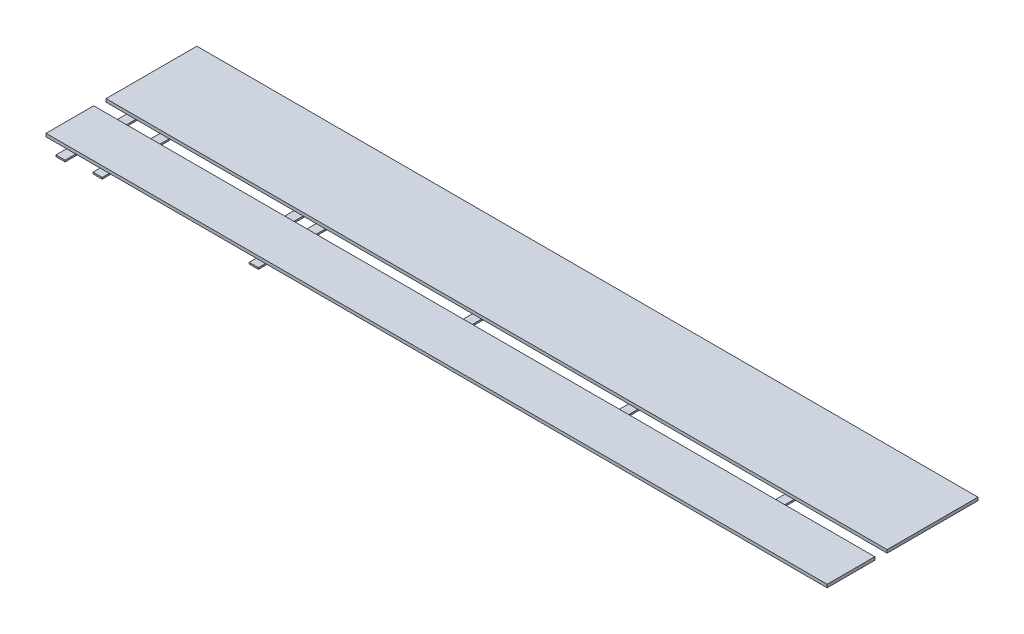
from build123d import *

# Parameters (mm, degrees)
SKETCH2_W             = 19.05
SKETCH2_H             = 251.02058
SKETCH2_R             = 2
BOSS_EXTRUDE1_DEPTH   = 3.175
BOSS_EXTRUDE1_2_DEPTH = 3.175
BOSS_EXTRUDE1_3_DEPTH = 3.175
SKETCH2_H_2           = 177.45456
BOSS_EXTRUDE1_4_DEPTH = 3.175
SKETCH2_H_3           = 125.44806
BOSS_EXTRUDE1_5_DEPTH = 3.175
SKETCH2_H_4           = 88.64092
BOSS_EXTRUDE1_6_DEPTH = 3.175
SKETCH2_H_5           = 265.9888
BOSS_EXTRUDE1_7_DEPTH = 3.175
BOSS_EXTRUDE2_DEPTH   = 6.35
BOSS_EXTRUDE2_2_DEPTH = 6.35


with BuildPart() as part:
    # Sketch2 → Boss-Extrude1 (new body)
    with BuildSketch(Plane(origin=(0, 0, 0), x_dir=(1, 0, 0), z_dir=(0, 1, 0))):
        with Locations((32.525, 177.50028)):
            Rectangle(SKETCH2_W, SKETCH2_H)
        with Locations((32.525, 246.79737)):
            Circle(SKETCH2_R, mode=Mode.SUBTRACT)
        with Locations((32.525, 108.20319)):
            Circle(SKETCH2_R, mode=Mode.SUBTRACT)
    extrude(amount=BOSS_EXTRUDE1_DEPTH)


with BuildPart() as body_2:
    # Sketch2 → Boss-Extrude1 2 (new body)
    with BuildSketch(Plane(origin=(0, 0, 0), x_dir=(1, 0, 0), z_dir=(0, 1, 0))):
        Polygon((299, 268.87678), (299, 86.12378), (318.05, 86.12378), (318.05, 268.87678), (308.525, 268.87678), align=None)
        with Locations((308.525, 227.93978)):
            Circle(SKETCH2_R, mode=Mode.SUBTRACT)
        with BuildLine():
            ThreePointArc((308.525, 125.06078), (306.525, 127.06078), (308.525, 129.06078))
            ThreePointArc((308.525, 129.06078), (310.525, 127.06078), (308.525, 125.06078))
        make_face(mode=Mode.SUBTRACT)
    extrude(amount=BOSS_EXTRUDE1_2_DEPTH)


with BuildPart() as body_3:
    # Sketch2 → Boss-Extrude1 3 (new body)
    with BuildSketch(Plane(origin=(0, 0, 0), x_dir=(1, 0, 0), z_dir=(0, 1, 0))):
        with Locations((354.525, 177.50028)):
            Rectangle(SKETCH2_W, SKETCH2_H)
        with Locations((354.525, 108.48022915)):
            Circle(SKETCH2_R, mode=Mode.SUBTRACT)
        with Locations((354.525, 246.52033085)):
            Circle(SKETCH2_R, mode=Mode.SUBTRACT)
    extrude(amount=BOSS_EXTRUDE1_3_DEPTH)


with BuildPart() as body_4:
    # Sketch2 → Boss-Extrude1 4 (new body)
    with BuildSketch(Plane(origin=(0, 0, 0), x_dir=(1, 0, 0), z_dir=(0, 1, 0))):
        with Locations((676.525, 177.50028)):
            Rectangle(SKETCH2_W, SKETCH2_H_2)
        with Locations((676.525, 128.708539125)):
            Circle(SKETCH2_R, mode=Mode.SUBTRACT)
        with Locations((676.525, 226.292020875)):
            Circle(SKETCH2_R, mode=Mode.SUBTRACT)
    extrude(amount=BOSS_EXTRUDE1_4_DEPTH)


with BuildPart() as body_5:
    # Sketch2 → Boss-Extrude1 5 (new body)
    with BuildSketch(Plane(origin=(0, 0, 0), x_dir=(1, 0, 0), z_dir=(0, 1, 0))):
        with Locations((998.525, 177.50028)):
            Rectangle(SKETCH2_W, SKETCH2_H_3)
        with Locations((998.525, 143.008361365)):
            Circle(SKETCH2_R, mode=Mode.SUBTRACT)
        with Locations((998.525, 211.992198635)):
            Circle(SKETCH2_R, mode=Mode.SUBTRACT)
    extrude(amount=BOSS_EXTRUDE1_5_DEPTH)


with BuildPart() as body_6:
    # Sketch2 → Boss-Extrude1 6 (new body)
    with BuildSketch(Plane(origin=(0, 0, 0), x_dir=(1, 0, 0), z_dir=(0, 1, 0))):
        with Locations((1320.525, 177.50028)):
            Rectangle(SKETCH2_W, SKETCH2_H_4)
        with Locations((1320.525, 153.11720963)):
            Circle(SKETCH2_R, mode=Mode.SUBTRACT)
        with Locations((1320.525, 201.88335037)):
            Circle(SKETCH2_R, mode=Mode.SUBTRACT)
    extrude(amount=BOSS_EXTRUDE1_6_DEPTH)


with BuildPart() as body_7:
    # Sketch2 → Boss-Extrude1 7 (new body)
    with BuildSketch(Plane(origin=(0, 0, 0), x_dir=(1, 0, 0), z_dir=(0, 1, 0))):
        with Locations((-36.475, 177.50028)):
            Rectangle(SKETCH2_W, SKETCH2_H_5)
        with Locations((-36.475, 250.91318)):
            Circle(SKETCH2_R, mode=Mode.SUBTRACT)
        with Locations((-36.475, 104.08738)):
            Circle(SKETCH2_R, mode=Mode.SUBTRACT)
    extrude(amount=BOSS_EXTRUDE1_7_DEPTH)


with BuildPart() as body_8:
    # Sketch3 → Boss-Extrude2 (new body)
    with BuildSketch(Plane(origin=(0, 3.175, 0), x_dir=(1, 0, 0), z_dir=(0, 1, 0))):
        Polygon((1311, 190.20028), (1330.05, 190.20028), (1521.795, 190.20028), (1521.795, 377.50028), (-88.375, 377.50028), (-88.375, 190.20028), (-46, 190.20028), (-26.95, 190.20028), align=None)
    extrude(amount=BOSS_EXTRUDE2_DEPTH)


with BuildPart() as body_9:
    # Sketch3 → Boss-Extrude2 2 (new body)
    with BuildSketch(Plane(origin=(0, 3.175, 0), x_dir=(1, 0, 0), z_dir=(0, 1, 0))):
        Polygon((1521.795, 164.80028), (1330.05, 164.80028), (1311, 164.80028), (-88.375, 164.80028), (-88.375, 66.50028), (1521.795, 66.50028), align=None)
    extrude(amount=BOSS_EXTRUDE2_2_DEPTH)


solid = Compound([part.part, body_2.part, body_3.part, body_4.part, body_5.part, body_6.part, body_7.part, body_8.part, body_9.part])
